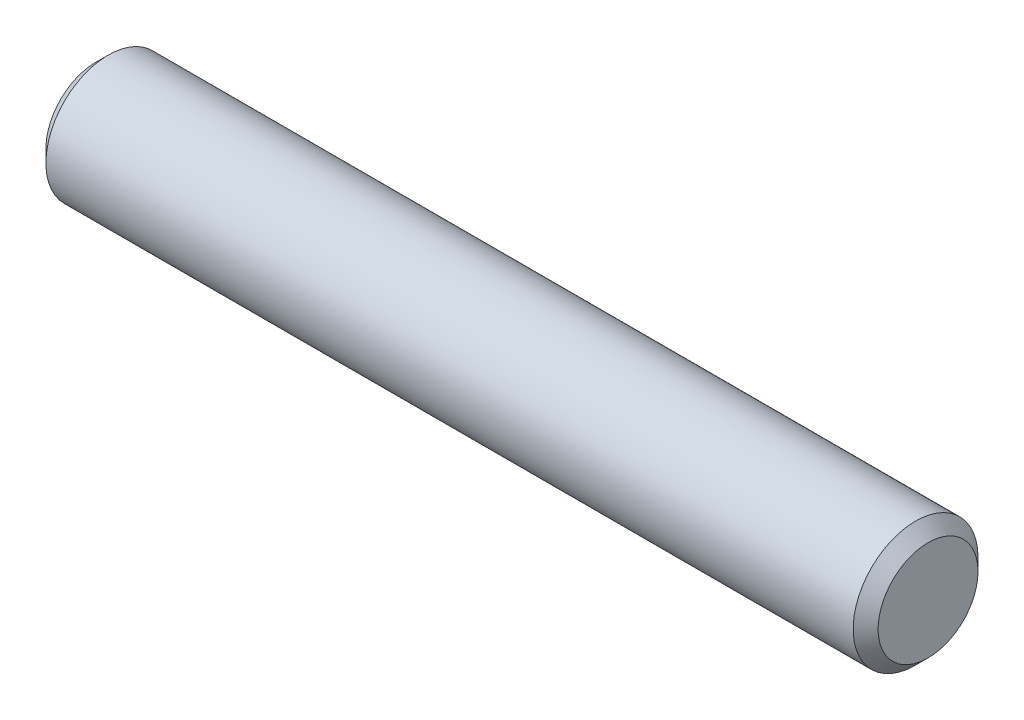
from build123d import *

# Parameters (mm, degrees)
SKETCH2_R           = 1.190625
EXTRUDE1_DEPTH      = 7.9375
EXTRUDE1_DEPTH_BACK = 7.9375
CHAMFER1_SIZE       = 0.238125


with BuildPart() as part:
    # Sketch2 → Extrude1 (new body, two sides)
    with BuildSketch(Plane(origin=(0, 0, 0), x_dir=(0, 0, -1), z_dir=(1, 0, 0))) as extrude1_sk:
        Circle(SKETCH2_R)
    extrude(amount=EXTRUDE1_DEPTH)
    extrude(extrude1_sk.sketch, amount=-EXTRUDE1_DEPTH_BACK)

    # Chamfer1
    chamfer1_edges = [part.edges().sort_by_distance(p)[0] for p in [
        (-7.9375, 0, 1.190625),
        (7.9375, 0, 1.190625),
    ]]
    chamfer(chamfer1_edges, length=CHAMFER1_SIZE)


solid = part.part
